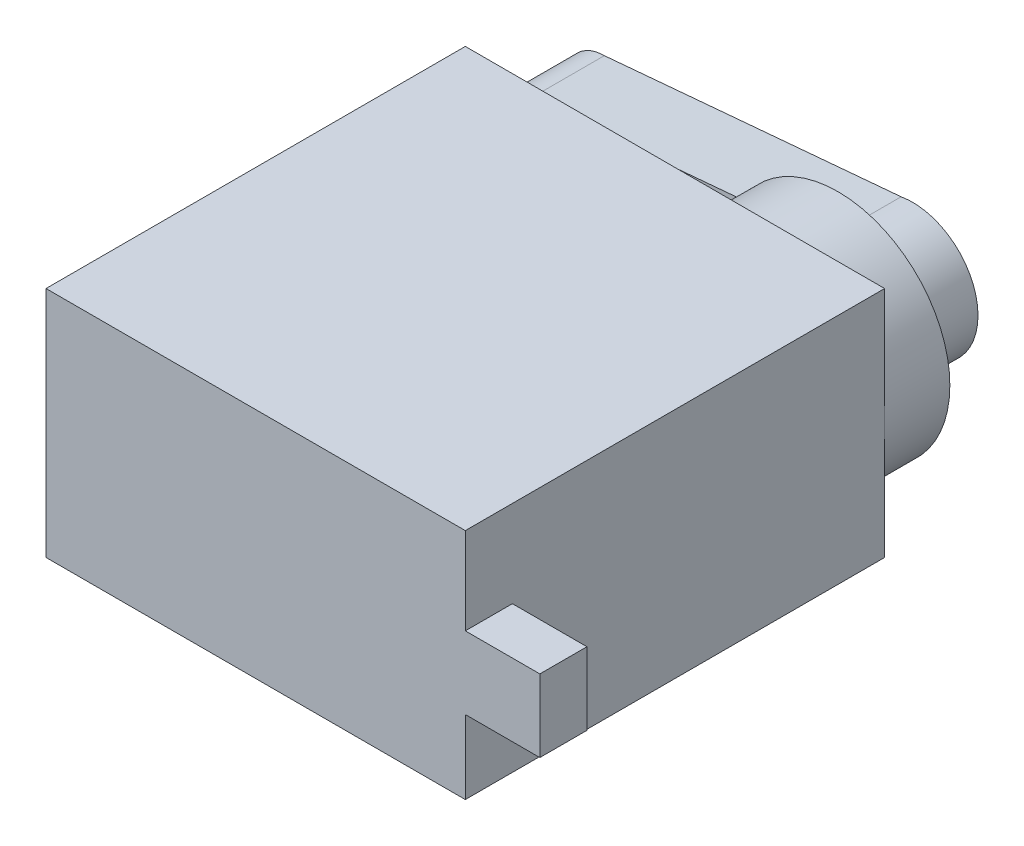
from build123d import *

# Parameters (mm, degrees)
SKETCH1_W           = 22.5
SKETCH1_H           = 12.5
BOSS_EXTRUDE1_DEPTH = 22.5
SKETCH2_R           = 6
BOSS_EXTRUDE2_DEPTH = 3.5
BOSS_EXTRUDE4_DEPTH = 4
SKETCH6_W           = 2.526093831
SKETCH6_H           = 3.888015028
BOSS_EXTRUDE5_DEPTH = 4


with BuildPart() as part:
    # Sketch1 → Boss-Extrude1 (new body)
    with BuildSketch(Plane.XY):
        Rectangle(SKETCH1_W, SKETCH1_H)
    extrude(amount=BOSS_EXTRUDE1_DEPTH)

    # Sketch2 → Boss-Extrude2 (add)
    with BuildSketch(Plane(origin=(0, 0, 0), x_dir=(-1, 0, 0), z_dir=(0, 0, -1))):
        with Locations((-5.25, 0)):
            Circle(SKETCH2_R)
    extrude(amount=BOSS_EXTRUDE2_DEPTH)

    # Sketch5 → Boss-Extrude4 (add)
    with BuildSketch(Plane(origin=(0, 0, -3.5), x_dir=(-1, 0, 0), z_dir=(0, 0, -1))):
        with BuildLine():
            Line((-4.635129487, 3.455724852), (11.29, 2.05))
            ThreePointArc((11.29, 2.05), (13.34, 0), (11.29, -2.05))
            Line((11.29, -2.05), (-4.635129487, -3.455724852))
            ThreePointArc((-4.635129487, -3.455724852), (-8.76, 0), (-4.635129487, 3.455724852))
        make_face()
    extrude(amount=BOSS_EXTRUDE4_DEPTH)

    # Sketch6 → Boss-Extrude5 (add)
    with BuildSketch(Plane(origin=(11.25, 0, 0), x_dir=(0, 0, -1), z_dir=(1, 0, 0))):
        with Locations((-21.236953085, -0.353333214)):
            Rectangle(SKETCH6_W, SKETCH6_H)
    extrude(amount=BOSS_EXTRUDE5_DEPTH)


solid = part.part
